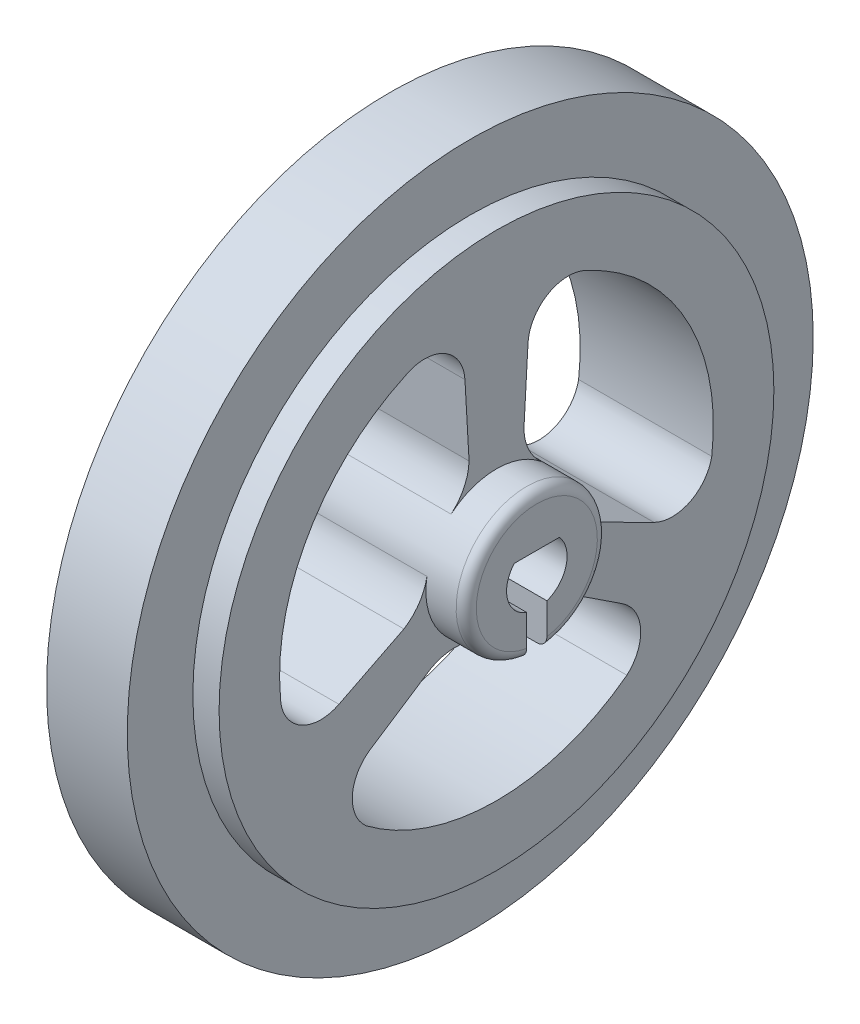
from build123d import *

# Parameters (mm, degrees)
RESSALTO_EXTRUS_O1_DEPTH      = 5.3
RESSALTO_EXTRUS_O1_DEPTH_BACK = 3.3
ESBO_O1_3_R                   = 13.75
RESSALTO_EXTRUS_O2_DEPTH      = 3.3
FILETE2_R                     = 0.5
ESBO_O2_R                     = 17
ESBO_O2_R_2                   = 13.75
RESSALTO_EXTRUS_O3_DEPTH      = 2


with BuildPart() as part:
    # Esbo_o1 → Ressalto-extrus_o1 (new body, two sides)
    with BuildSketch(Plane(origin=(0, 0, 0), x_dir=(0, 0, -1), z_dir=(1, 0, 0))) as ressalto_extrus_o1_sk:
        with BuildLine():
            ThreePointArc((0.5, -1.414213562), (1.4531398, -0.37200097), (1.118033989, 1))
            Line((1.118033989, 1), (-1.118033989, 1))
            ThreePointArc((-1.118033989, 1), (-1.4531398, -0.37200097), (-0.5, -1.414213562))
            Line((-0.5, -1.414213562), (-0.5, -3.464101615))
            ThreePointArc((-0.5, -3.464101615), (0, 3.5), (0.5, -3.464101615))
            Line((0.5, -3.464101615), (0.5, -1.414213562))
        make_face()
    extrude(amount=RESSALTO_EXTRUS_O1_DEPTH)
    extrude(ressalto_extrus_o1_sk.sketch, amount=-RESSALTO_EXTRUS_O1_DEPTH_BACK)

    # Esbo_o1_3 → Ressalto-extrus_o2 (add, symmetric)
    with BuildSketch(Plane(origin=(0, 0, 0), x_dir=(0, 0, -1), z_dir=(1, 0, 0))):
        Circle(ESBO_O1_3_R)
        with BuildLine():
            ThreePointArc((3.446771953, 0.608081497), (3.031088913, -1.75), (1.196771953, -3.28903282))
            ThreePointArc((1.196771953, -3.28903282), (2.228560776, -3.144612223), (3.229618168, -3.433280857))
            Line((3.229618168, -3.433280857), (6.244929793, -5.410607922))
            ThreePointArc((6.244929793, -5.410607922), (7.143531761, -6.946693722), (6.462297299, -8.590763273))
            ThreePointArc((6.462297299, -8.590763273), (0, -10.75), (-6.462297299, -8.590763273))
            ThreePointArc((-6.462297299, -8.590763273), (-7.143531761, -6.946693722), (-6.244929793, -5.410607922))
            Line((-6.244929793, -5.410607922), (-3.229618168, -3.433280857))
            ThreePointArc((-3.229618168, -3.433280857), (-2.228560776, -3.144612223), (-1.196771953, -3.28903282))
            ThreePointArc((-1.196771953, -3.28903282), (-3.031088913, -1.75), (-3.446771953, 0.608081497))
            ThreePointArc((-3.446771953, 0.608081497), (-3.837594458, -0.357684134), (-4.588117525, -1.08029095))
            Line((-4.588117525, -1.08029095), (-7.808188807, -2.702963885))
            ThreePointArc((-7.808188807, -2.702963885), (-9.742921821, -2.628468224), (-10.707946608, -0.949936544))
            ThreePointArc((-10.707946608, -0.949936544), (-9.309773091, 5.375), (-4.531304125, 9.748322057))
            ThreePointArc((-4.531304125, 9.748322057), (-2.595140656, 9.751851916), (-1.563259014, 8.113571807))
            Line((-1.563259014, 8.113571807), (-1.358499357, 4.513571807))
            ThreePointArc((-1.358499357, 4.513571807), (-1.609033682, 3.502296357), (-2.25, 2.680951324))
            ThreePointArc((-2.25, 2.680951324), (0, 3.5), (2.25, 2.680951324))
            ThreePointArc((2.25, 2.680951324), (1.609033682, 3.502296357), (1.358499357, 4.513571807))
            Line((1.358499357, 4.513571807), (1.563259014, 8.113571807))
            ThreePointArc((1.563259014, 8.113571807), (2.595140656, 9.751851916), (4.531304125, 9.748322057))
            ThreePointArc((4.531304125, 9.748322057), (9.396801436, 5.221362156), (10.670967882, -1.301131991))
            ThreePointArc((10.670967882, -1.301131991), (9.587779116, -2.713133117), (7.808188807, -2.702963885))
            Line((7.808188807, -2.702963885), (4.588117525, -1.08029095))
            ThreePointArc((4.588117525, -1.08029095), (3.837594458, -0.357684134), (3.446771953, 0.608081497))
        make_face(mode=Mode.SUBTRACT)
    extrude(amount=RESSALTO_EXTRUS_O2_DEPTH, both=True)

    # Filete2
    filete2_edges = [part.edges().sort_by_distance(p)[0] for p in [
        (5.3, 3.5, 0),
    ]]
    fillet(filete2_edges, radius=FILETE2_R)

    # Esbo_o2 → Ressalto-extrus_o3 (add, symmetric)
    with BuildSketch(Plane(origin=(0, 0, 0), x_dir=(0, 0, -1), z_dir=(1, 0, 0))):
        Circle(ESBO_O2_R)
        Circle(ESBO_O2_R_2, mode=Mode.SUBTRACT)
    extrude(amount=RESSALTO_EXTRUS_O3_DEPTH, both=True)


solid = part.part
